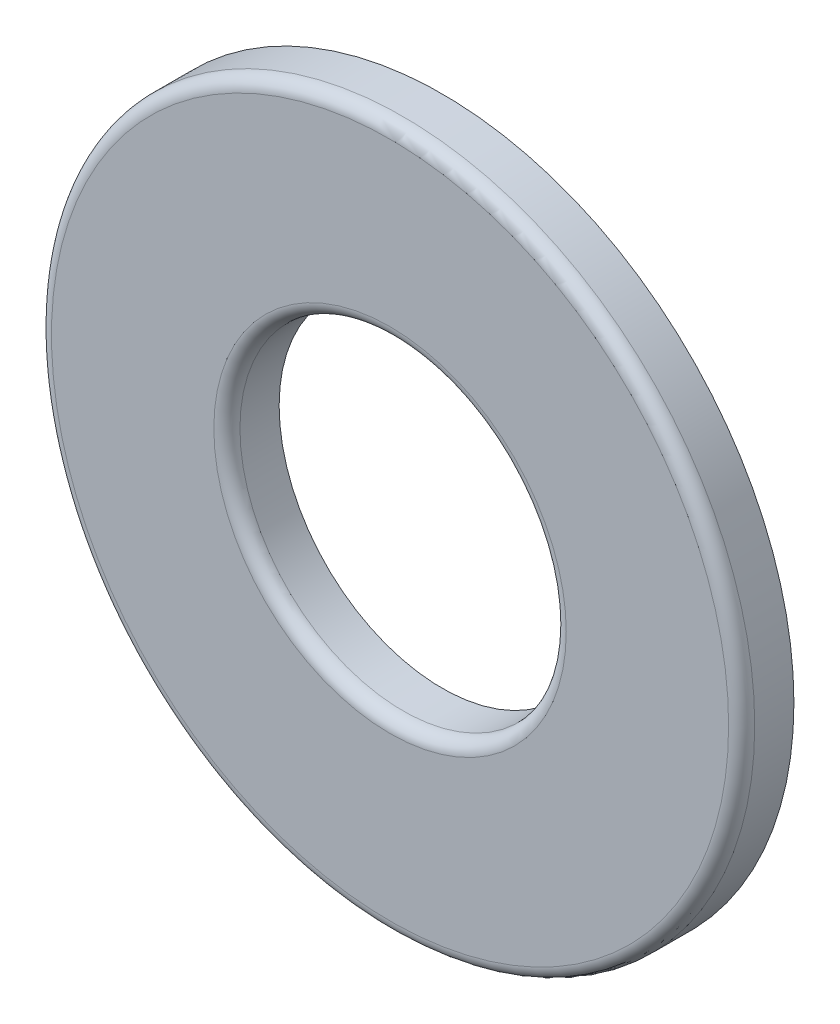
from build123d import *

# Parameters (mm, degrees)
SKETCH3_R                = 5.55625
SKETCH3_R_2              = 2.5781
BOSS_EXTRUDE1_DEPTH      = 0.41275
BOSS_EXTRUDE1_DEPTH_BACK = 0.41275
FILLET1_R                = 0.206375


with BuildPart() as part:
    # Sketch3 → Boss-Extrude1 (new body, two sides)
    with BuildSketch(Plane.XY) as boss_extrude1_sk:
        Circle(SKETCH3_R)
        Circle(SKETCH3_R_2, mode=Mode.SUBTRACT)
    extrude(amount=BOSS_EXTRUDE1_DEPTH)
    extrude(boss_extrude1_sk.sketch, amount=-BOSS_EXTRUDE1_DEPTH_BACK)

    # Fillet1
    fillet1_edges = [part.edges().sort_by_distance(p)[0] for p in [
        (-5.55625, 0, 0.41275),
        (-2.5781, 0, 0.41275),
    ]]
    fillet(fillet1_edges, radius=FILLET1_R)


solid = part.part
